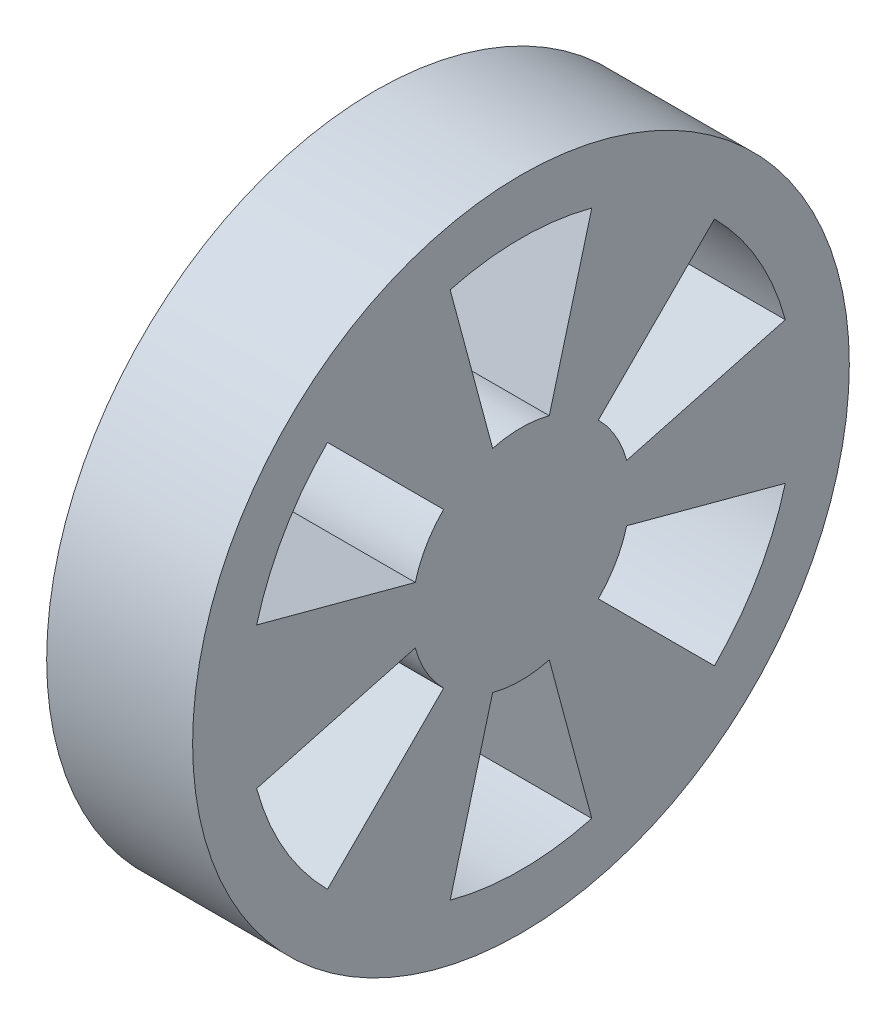
from build123d import *

# Parameters (mm, degrees)
SKETCH_1_R          = 10
EXTRUDE_1_DEPTH     = 20
SKETCH_2_R          = 45
EXTRUDE_2_DEPTH     = 20
CUT_EXTRUDE_1_DEPTH = 20


with BuildPart() as part:
    # 草图1 → 凸台-拉伸1 (new body)
    with BuildSketch(Plane(origin=(0, 0, 0), x_dir=(0, 0, -1), z_dir=(1, 0, 0))):
        Circle(SKETCH_1_R)
    extrude(amount=EXTRUDE_1_DEPTH)

    # 草图2 → 凸台-拉伸2 (add)
    with BuildSketch(Plane(origin=(20, 0, 0), x_dir=(0, 0, -1), z_dir=(1, 0, 0))):
        Circle(SKETCH_2_R)
    extrude(amount=EXTRUDE_2_DEPTH)

    # 草图3 → 切除-拉伸1 (cut)
    with BuildSketch(Plane.ZY.offset(-20)):
        with BuildLine():
            Line((-9.705714191, 36.222218486), (-3.882285677, 14.488887394))
            ThreePointArc((-3.882285677, 14.488887394), (0, 15), (3.882285677, 14.488887394))
            Line((3.882285677, 14.488887394), (9.705714191, 36.222218486))
            ThreePointArc((9.705714191, 36.222218486), (0, 37.5), (-9.705714191, 36.222218486))
        make_face()
        with BuildLine():
            Line((26.516504294, 26.516504294), (10.606601718, 10.606601718))
            ThreePointArc((10.606601718, 10.606601718), (12.990381057, 7.5), (14.488887394, 3.882285677))
            Line((14.488887394, 3.882285677), (36.222218486, 9.705714191))
            ThreePointArc((36.222218486, 9.705714191), (32.475952642, 18.75), (26.516504294, 26.516504294))
        make_face()
        with BuildLine():
            Line((36.222218486, -9.705714191), (14.488887394, -3.882285677))
            ThreePointArc((14.488887394, -3.882285677), (12.990381057, -7.5), (10.606601718, -10.606601718))
            Line((10.606601718, -10.606601718), (26.516504294, -26.516504294))
            ThreePointArc((26.516504294, -26.516504294), (32.475952642, -18.75), (36.222218486, -9.705714191))
        make_face()
        with BuildLine():
            Line((9.705714191, -36.222218486), (3.882285677, -14.488887394))
            ThreePointArc((3.882285677, -14.488887394), (0, -15), (-3.882285677, -14.488887394))
            Line((-3.882285677, -14.488887394), (-9.705714191, -36.222218486))
            ThreePointArc((-9.705714191, -36.222218486), (0, -37.5), (9.705714191, -36.222218486))
        make_face()
        with BuildLine():
            Line((-26.516504294, -26.516504294), (-10.606601718, -10.606601718))
            ThreePointArc((-10.606601718, -10.606601718), (-12.990381057, -7.5), (-14.488887394, -3.882285677))
            Line((-14.488887394, -3.882285677), (-36.222218486, -9.705714191))
            ThreePointArc((-36.222218486, -9.705714191), (-32.475952642, -18.75), (-26.516504294, -26.516504294))
        make_face()
        with BuildLine():
            Line((-36.222218486, 9.705714191), (-14.488887394, 3.882285677))
            ThreePointArc((-14.488887394, 3.882285677), (-12.990381057, 7.5), (-10.606601718, 10.606601718))
            Line((-10.606601718, 10.606601718), (-26.516504294, 26.516504294))
            ThreePointArc((-26.516504294, 26.516504294), (-32.475952642, 18.75), (-36.222218486, 9.705714191))
        make_face()
    extrude(amount=-CUT_EXTRUDE_1_DEPTH, mode=Mode.SUBTRACT)


solid = part.part
